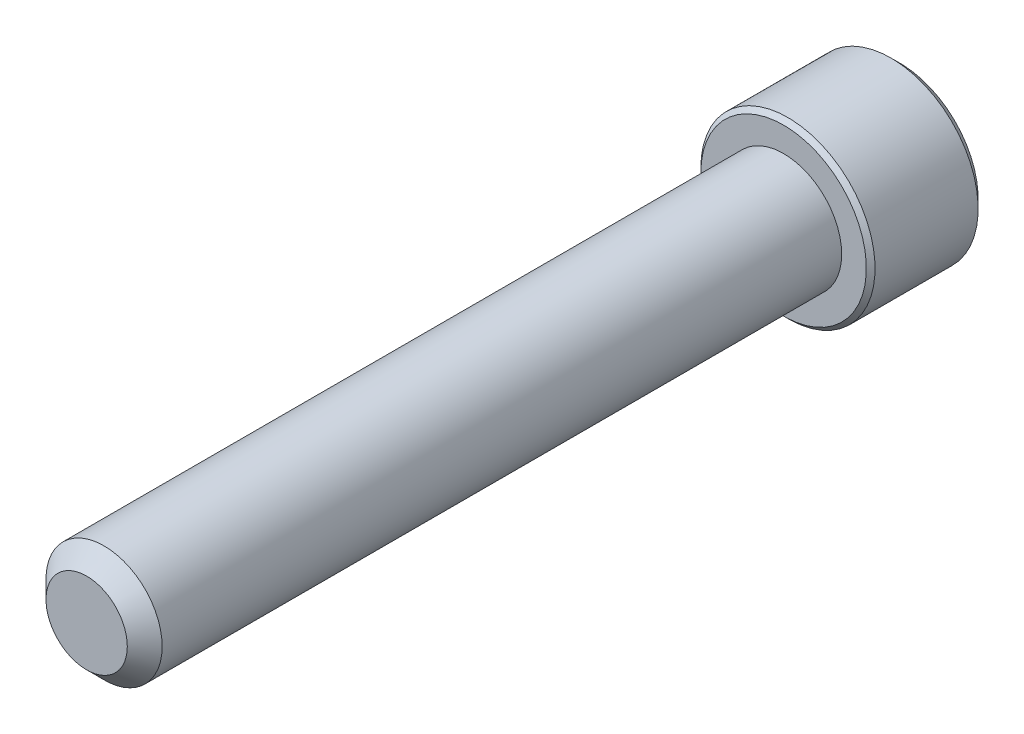
from build123d import *

# Parameters (mm, degrees)
SKETCH1_R          = 3.175
EXTRUDE1_DEPTH     = 38.1
CHAMFER3_SIZE      = 0.9525
SKETCH6_R          = 4.7625
EXTRUDE2_DEPTH     = 6.35
CUT_EXTRUDE1_DEPTH = 3.571875
CHAMFER1_SIZE      = 0.47625
CHAMFER2_SIZE      = 0.238125


with BuildPart() as part:
    # Sketch1 → Extrude1 (new body)
    with BuildSketch(Plane.XY):
        Circle(SKETCH1_R)
    extrude(amount=-EXTRUDE1_DEPTH)

    # Chamfer3
    chamfer3_edges = [part.edges().sort_by_distance(p)[0] for p in [
        (-3.175, 0, 0),
    ]]
    chamfer(chamfer3_edges, length=CHAMFER3_SIZE)

    # Sketch6 → Extrude2 (add)
    with BuildSketch(Plane(origin=(0, 0, -38.1), x_dir=(-1, 0, 0), z_dir=(0, 0, -1))):
        Circle(SKETCH6_R)
    extrude(amount=EXTRUDE2_DEPTH)

    # Sketch7 → Cut-Extrude1 (cut)
    with BuildSketch(Plane(origin=(0, 0, -44.45), x_dir=(-1, 0, 0), z_dir=(0, 0, -1))):
        Polygon((0, 2.749630657), (-2.38125, 1.374815329), (-2.38125, -1.374815329), (0, -2.749630657), (2.38125, -1.374815329), (2.38125, 1.374815329), align=None)
    extrude(amount=-CUT_EXTRUDE1_DEPTH, mode=Mode.SUBTRACT)

    # Cut-Extrude2 cone 1 section (through the dimple's axis) → Cut-Extrude2 (revolve, cut)
    with BuildSketch(Plane(origin=(0, 0, -44.45), x_dir=(0, 1, 0), z_dir=(1, 0, 0))):
        Polygon((0, 0), (2.749630657, 0), (0, 2.749630657), align=None)
    revolve(axis=Axis((0, 0, -44.45), (0, 0, 1)), mode=Mode.SUBTRACT)

    # Chamfer1
    chamfer1_edges = [part.edges().sort_by_distance(p)[0] for p in [
        (4.7625, 0, -44.45),
    ]]
    chamfer(chamfer1_edges, length=CHAMFER1_SIZE)

    # Chamfer2
    chamfer2_edges = [part.edges().sort_by_distance(p)[0] for p in [
        (4.7625, 0, -38.1),
    ]]
    chamfer(chamfer2_edges, length=CHAMFER2_SIZE)


solid = part.part
